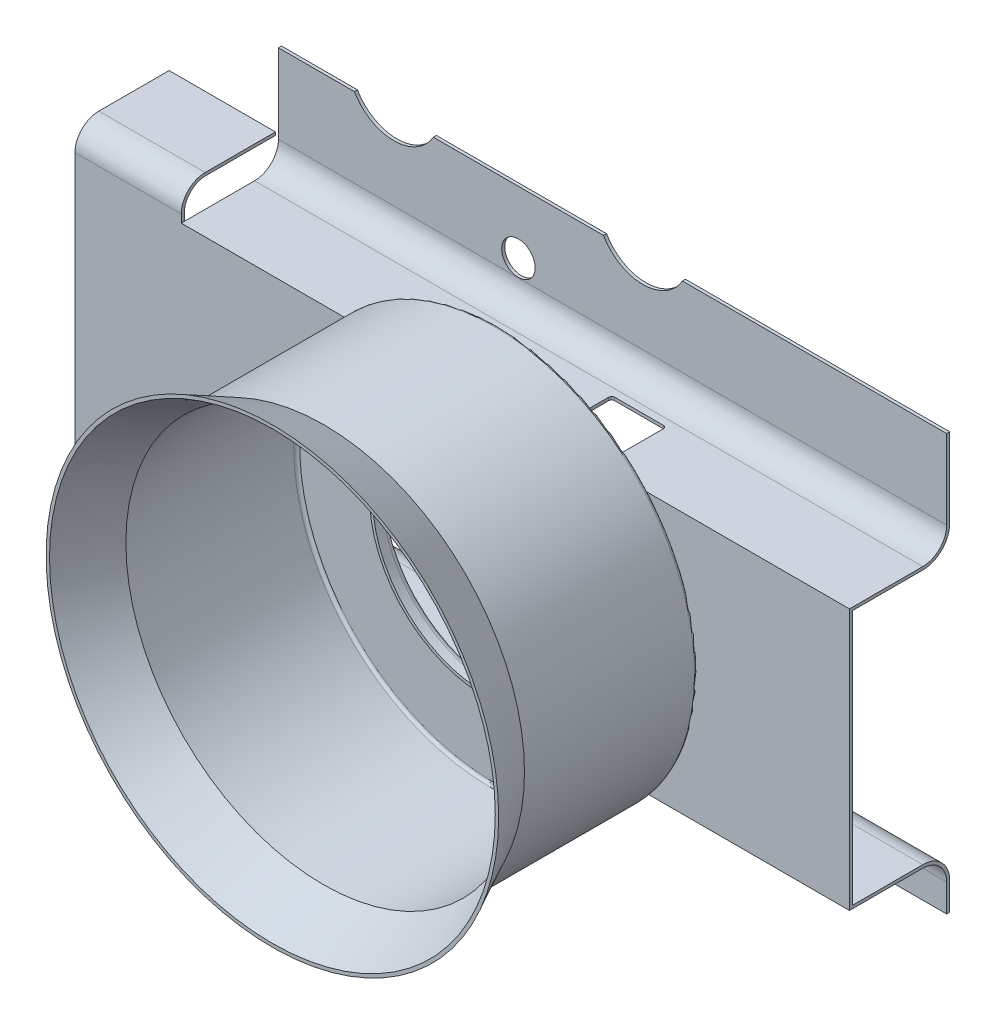
from build123d import *

# Parameters (mm, degrees)
BOSS_EXTRUDE2_DEPTH = 12.7
BOSS_EXTRUDE3_DEPTH = 43.18
BOSS_EXTRUDE4_DEPTH = 8.89
SKETCH10_R          = 9.398
CUT_EXTRUDE2_DEPTH  = 9.398
FILLET1_R           = 0.508
SKETCH11_R          = 1.397
CUT_EXTRUDE3_DEPTH  = 0.254
SKETCH12_R          = 3.81
CUT_EXTRUDE5_DEPTH  = 2.54
CUT_EXTRUDE6_REACH  = 31.845


with BuildPart() as part:
    # Sketch2 → Revolve1 (revolve)
    with BuildSketch(Plane(origin=(0, 0, 0), x_dir=(0, 0, -1), z_dir=(1, 0, 0))):
        with BuildLine():
            Line((0, 18.923), (4.318, 16.764))
            Line((4.318, 16.764), (18.542, 16.764))
            ThreePointArc((18.542, 16.764), (18.721605122, 16.689605122), (18.796, 16.51))
            Line((18.796, 16.51), (18.796, 9.398))
            Line((18.796, 9.398), (17.78, 9.398))
            Line((17.78, 9.398), (17.78, 9.652))
            Line((17.78, 9.652), (18.542, 9.652))
            Line((18.542, 9.652), (18.542, 16.256))
            ThreePointArc((18.542, 16.256), (18.467605122, 16.435605122), (18.288, 16.51))
            Line((18.288, 16.51), (4.258038734, 16.51))
            Line((4.258038734, 16.51), (0, 18.639019367))
            Line((0, 18.639019367), (0, 18.923))
        make_face()
    revolve(axis=Axis((0, 0, 8.948655539), (0, 0, -1)))



with BuildPart() as body_2:
    # Sketch6 → Boss-Extrude2 (new body)
    with BuildSketch(Plane(origin=(16.764, 0, 0), x_dir=(0, 0, -1), z_dir=(1, 0, 0))):
        with BuildLine():
            Line((26.924, 19.558), (27.178, 19.558))
            Line((27.178, 19.558), (27.178, 12.92200108))
            ThreePointArc((27.178, 12.92200108), (26.517818368, 11.328181632), (24.92399892, 10.668))
            Line((24.92399892, 10.668), (19.05, 10.668))
            Line((19.05, 10.668), (19.05, -10.668))
            Line((19.05, -10.668), (24.92399892, -10.668))
            ThreePointArc((24.92399892, -10.668), (26.517818368, -11.328181632), (27.178, -12.92200108))
            Line((27.178, -12.92200108), (27.178, -15.24))
            Line((27.178, -15.24), (26.924, -15.24))
            Line((26.924, -15.24), (26.924, -12.92200108))
            ThreePointArc((26.924, -12.92200108), (26.338213246, -11.507786754), (24.92399892, -10.922))
            Line((24.92399892, -10.922), (18.796, -10.922))
            Line((18.796, -10.922), (18.796, 10.922))
            Line((18.796, 10.922), (24.92399892, 10.922))
            ThreePointArc((24.92399892, 10.922), (26.338213246, 11.507786754), (26.924, 12.92200108))
            Line((26.924, 12.92200108), (26.924, 19.558))
        make_face()
    extrude(amount=BOSS_EXTRUDE2_DEPTH)


with BuildPart() as part_1:
    add(part.part)

    add(body_2.part)  # Boss-Extrude3 merges body 2
    # Sketch8 → Boss-Extrude3 (add)
    with BuildSketch(Plane.ZY.offset(-16.764)):
        with BuildLine():
            Line((-26.924, 12.92200108), (-26.924, 19.558))
            Line((-26.924, 19.558), (-27.178, 19.558))
            Line((-27.178, 19.558), (-27.178, 12.92200108))
            ThreePointArc((-27.178, 12.92200108), (-26.517818368, 11.328181632), (-24.92399892, 10.668))
            Line((-24.92399892, 10.668), (-19.05, 10.668))
            Line((-19.05, 10.668), (-19.05, -10.668))
            Line((-19.05, -10.668), (-24.92399892, -10.668))
            ThreePointArc((-24.92399892, -10.668), (-26.517818368, -11.328181632), (-27.178, -12.92200108))
            Line((-27.178, -12.92200108), (-27.178, -15.24))
            Line((-27.178, -15.24), (-26.924, -15.24))
            Line((-26.924, -15.24), (-26.924, -12.92200108))
            ThreePointArc((-26.924, -12.92200108), (-26.338213246, -11.507786754), (-24.92399892, -10.922))
            Line((-24.92399892, -10.922), (-18.796, -10.922))
            Line((-18.796, -10.922), (-18.796, 10.922))
            Line((-18.796, 10.922), (-24.92399892, 10.922))
            ThreePointArc((-24.92399892, 10.922), (-26.338213246, 11.507786754), (-26.924, 12.92200108))
        make_face()
    extrude(amount=BOSS_EXTRUDE3_DEPTH)

    # Sketch9 → Boss-Extrude4 (add)
    with BuildSketch(Plane.ZY.offset(26.416)):
        with BuildLine():
            Line((-18.796, 11.58899892), (-18.796, -11.58899892))
            ThreePointArc((-18.796, -11.58899892), (-19.381786754, -13.003213246), (-20.79600108, -13.589))
            Line((-20.79600108, -13.589), (-26.67, -13.589))
            Line((-26.67, -13.589), (-26.67, -13.335))
            Line((-26.67, -13.335), (-20.79600108, -13.335))
            ThreePointArc((-20.79600108, -13.335), (-19.561391876, -12.823608124), (-19.05, -11.58899892))
            Line((-19.05, -11.58899892), (-19.05, 11.58899892))
            ThreePointArc((-19.05, 11.58899892), (-19.599773222, 12.827111013), (-20.855647788, 13.335))
            Line((-20.855647788, 13.335), (-26.67, 13.335))
            Line((-26.67, 13.335), (-26.67, 13.589))
            Line((-26.67, 13.589), (-20.79600108, 13.589))
            ThreePointArc((-20.79600108, 13.589), (-19.381786754, 13.003213246), (-18.796, 11.58899892))
        make_face()
    extrude(amount=BOSS_EXTRUDE4_DEPTH)

    # Sketch10 → Cut-Extrude2 (cut)
    with BuildSketch(Plane.XY.offset(-18.796)):
        Circle(SKETCH10_R)
    extrude(amount=-CUT_EXTRUDE2_DEPTH, mode=Mode.SUBTRACT)

    # Fillet1
    fillet1_edges = [part_1.edges().sort_by_distance(p)[0] for p in [
        (-9.398, 0, -19.05),
    ]]
    fillet(fillet1_edges, radius=FILLET1_R)

    # Sketch11 → Cut-Extrude3 (cut)
    with BuildSketch(Plane(origin=(0, 0, -27.178), x_dir=(-1, 0, 0), z_dir=(0, 0, -1))):
        with Locations((6.35, 14.351)):
            Circle(SKETCH11_R)
    extrude(amount=-CUT_EXTRUDE3_DEPTH, mode=Mode.SUBTRACT)

    # Sketch12 → Cut-Extrude5 (cut)
    with BuildSketch(Plane(origin=(0, 0, -27.178), x_dir=(-1, 0, 0), z_dir=(0, 0, -1))):
        with Locations((16.764, 21.463)):
            Circle(SKETCH12_R)
        with Locations((-4.064, 21.463)):
            Circle(SKETCH12_R)
    extrude(amount=-CUT_EXTRUDE5_DEPTH, mode=Mode.SUBTRACT)

    # Sketch13 → Cut-Extrude6 (cut, up to next)
    with BuildSketch(Plane(origin=(0, 10.922, 0), x_dir=(1, 0, 0), z_dir=(0, 1, 0)), mode=Mode.PRIVATE) as cut_extrude6_sk1:
        with BuildLine():
            Line((4.318, 24.309866454), (8.382, 24.309866454))
            ThreePointArc((8.382, 24.309866454), (8.561605122, 24.235471576), (8.636, 24.055866454))
            Line((8.636, 24.055866454), (8.636, 19.991866454))
            ThreePointArc((8.636, 19.991866454), (8.561605122, 19.812261332), (8.382, 19.737866454))
            Line((8.382, 19.737866454), (4.318, 19.737866454))
            ThreePointArc((4.318, 19.737866454), (4.138394878, 19.812261332), (4.064, 19.991866454))
            Line((4.064, 19.991866454), (4.064, 24.055866454))
            ThreePointArc((4.064, 24.055866454), (4.138394878, 24.235471576), (4.318, 24.309866454))
        make_face()
    cut_extrude6_tool1 = extrude(cut_extrude6_sk1.sketch, amount=-CUT_EXTRUDE6_REACH, mode=Mode.PRIVATE) & part_1.part
    add(cut_extrude6_tool1.solids().sort_by_distance((6.35, 10.922, -22.023866))[0], mode=Mode.SUBTRACT)


solid = part_1.part
